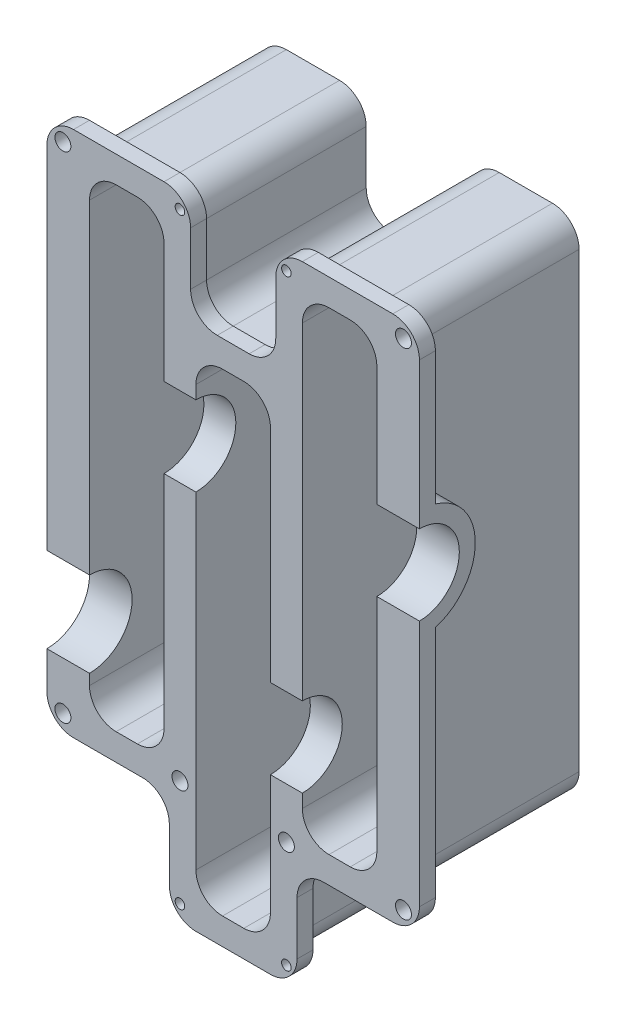
from build123d import *

# Parameters (mm, degrees)
SKETCH1_W           = 70
SKETCH1_H           = 119
BOSS_EXTRUDE1_DEPTH = 35
SKETCH2_R           = 8
CUT_EXTRUDE1_DEPTH  = 8
CUT_EXTRUDE2_DEPTH  = 32
SKETCH4_R           = 7.5
CUT_EXTRUDE3_DEPTH  = 8
SKETCH5_W           = 16
SKETCH5_H           = 20
SKETCH5_W_2         = 23
CUT_EXTRUDE4_DEPTH  = 36
CUT_EXTRUDE5_DEPTH  = 5
SKETCH7_W           = 18
SKETCH7_H           = 32
CUT_EXTRUDE6_DEPTH  = 2
SKETCH8_W           = 32
SKETCH8_H           = 22
CUT_EXTRUDE7_DEPTH  = 2
SKETCH9_W           = 22
SKETCH9_H           = 32
CUT_EXTRUDE8_DEPTH  = 2
SKETCH10_W          = 32
SKETCH10_H          = 18
CUT_EXTRUDE9_DEPTH  = 2
SKETCH11_W          = 25
SKETCH11_H          = 32
CUT_EXTRUDE10_DEPTH = 2
CUT_EXTRUDE11_DEPTH = 5
SKETCH13_W          = 22
SKETCH13_H          = 32
CUT_EXTRUDE12_DEPTH = 2
SKETCH14_W          = 32
SKETCH14_H          = 18
CUT_EXTRUDE17_DEPTH = 2
SKETCH18_W          = 18
SKETCH18_H          = 32
CUT_EXTRUDE18_DEPTH = 2
SKETCH20_W          = 32
SKETCH20_H          = 22
CUT_EXTRUDE19_DEPTH = 2
SKETCH21_W          = 20
SKETCH21_H          = 32
CUT_EXTRUDE20_DEPTH = 2
FILLET1_R           = 5
FILLET2_R           = 5
FILLET3_R           = 5
SKETCH23_R          = 1.5
CUT_EXTRUDE21_DEPTH = 10
SKETCH24_R          = 0.9
CUT_EXTRUDE22_DEPTH = 10
BOSS_EXTRUDE2_DEPTH = 6
BOSS_EXTRUDE3_DEPTH = 6


with BuildPart() as part:
    # Sketch1 → Boss-Extrude1 (new body)
    with BuildSketch(Plane.XY):
        Rectangle(SKETCH1_W, SKETCH1_H)
    extrude(amount=BOSS_EXTRUDE1_DEPTH)

    # Sketch2 → Cut-Extrude1 (cut)
    with BuildSketch(Plane.ZY.offset(35)):
        with Locations((35, -19.5)):
            Circle(SKETCH2_R)
    extrude(amount=-CUT_EXTRUDE1_DEPTH, mode=Mode.SUBTRACT)

    # Sketch3 → Cut-Extrude2 (cut)
    with BuildSketch(Plane.XY.offset(35)):
        Polygon((-27, 54.5), (-13, 54.5), (-13, 27), (-7, 27), (-7, 34.5), (7, 34.5), (7, -12), (13, -12), (13, 54.5), (27, 54.5), (27, -34.5), (13, -34.5), (13, -27), (7, -27), (7, -54.5), (-7, -54.5), (-7, 12), (-13, 12), (-13, -34.5), (-27, -34.5), align=None)
    extrude(amount=-CUT_EXTRUDE2_DEPTH, mode=Mode.SUBTRACT)

    # Sketch4 → Cut-Extrude3 (cut)
    with BuildSketch(Plane(origin=(35, 0, 0), x_dir=(0, 0, -1), z_dir=(1, 0, 0))):
        with Locations((-35, 19.5)):
            Circle(SKETCH4_R)
    extrude(amount=-CUT_EXTRUDE3_DEPTH, mode=Mode.SUBTRACT)

    # Sketch5 → Cut-Extrude4 (cut, through all)
    with BuildSketch(Plane.XY.offset(35)):
        with Locations((0, 49.5)):
            Rectangle(SKETCH5_W, SKETCH5_H)
        with Locations((-23.5, -49.5)):
            Rectangle(SKETCH5_W_2, SKETCH5_H)
        with Locations((23.5, -49.5)):
            Rectangle(SKETCH5_W_2, SKETCH5_H)
    extrude(amount=-CUT_EXTRUDE4_DEPTH, mode=Mode.SUBTRACT)

    # Sketch6 → Cut-Extrude5 (cut)
    with BuildSketch(Plane.ZY.offset(35)):
        with BuildLine():
            Line((0, -39.5), (0, 59.5))
            Line((0, 59.5), (32, 59.5))
            Line((32, 59.5), (32, -8.916994756))
            ThreePointArc((32, -8.916994756), (24, -19.5), (32, -30.083005244))
            Line((32, -30.083005244), (32, -39.5))
            Line((32, -39.5), (0, -39.5))
        make_face()
    extrude(amount=-CUT_EXTRUDE5_DEPTH, mode=Mode.SUBTRACT)

    # Sketch7 → Cut-Extrude6 (cut)
    with BuildSketch(Plane.XZ.offset(39.5)):
        with Locations((-21, 16)):
            Rectangle(SKETCH7_W, SKETCH7_H)
    extrude(amount=-CUT_EXTRUDE6_DEPTH, mode=Mode.SUBTRACT)

    # Sketch8 → Cut-Extrude7 (cut)
    with BuildSketch(Plane.ZY.offset(12)):
        with Locations((16, -48.5)):
            Rectangle(SKETCH8_W, SKETCH8_H)
    extrude(amount=-CUT_EXTRUDE7_DEPTH, mode=Mode.SUBTRACT)

    # Sketch9 → Cut-Extrude8 (cut)
    with BuildSketch(Plane.XZ.offset(59.5)):
        with Locations((1, 16)):
            Rectangle(SKETCH9_W, SKETCH9_H)
    extrude(amount=-CUT_EXTRUDE8_DEPTH, mode=Mode.SUBTRACT)

    # Sketch10 → Cut-Extrude9 (cut)
    with BuildSketch(Plane(origin=(12, 0, 0), x_dir=(0, 0, -1), z_dir=(1, 0, 0))):
        with Locations((-16, -48.5)):
            Rectangle(SKETCH10_W, SKETCH10_H)
    extrude(amount=-CUT_EXTRUDE9_DEPTH, mode=Mode.SUBTRACT)

    # Sketch11 → Cut-Extrude10 (cut)
    with BuildSketch(Plane.XZ.offset(39.5)):
        with Locations((22.5, 16)):
            Rectangle(SKETCH11_W, SKETCH11_H)
    extrude(amount=-CUT_EXTRUDE10_DEPTH, mode=Mode.SUBTRACT)

    # Sketch12 → Cut-Extrude11 (cut)
    with BuildSketch(Plane(origin=(35, 0, 0), x_dir=(0, 0, -1), z_dir=(1, 0, 0))):
        with BuildLine():
            Line((-32, 59.5), (0, 59.5))
            Line((0, 59.5), (0, -37.5))
            Line((0, -37.5), (-32, -37.5))
            Line((-32, -37.5), (-32, 9.437694101))
            ThreePointArc((-32, 9.437694101), (-24.5, 19.5), (-32, 29.562305899))
            Line((-32, 29.562305899), (-32, 59.5))
        make_face()
    extrude(amount=-CUT_EXTRUDE11_DEPTH, mode=Mode.SUBTRACT)

    # Sketch13 → Cut-Extrude12 (cut)
    with BuildSketch(Plane(origin=(0, 59.5, 0), x_dir=(1, 0, 0), z_dir=(0, 1, 0))):
        with Locations((19, -16)):
            Rectangle(SKETCH13_W, SKETCH13_H)
    extrude(amount=-CUT_EXTRUDE12_DEPTH, mode=Mode.SUBTRACT)

    # Sketch14 → Cut-Extrude17 (cut)
    with BuildSketch(Plane.ZY.offset(-8)):
        with Locations((16, 48.5)):
            Rectangle(SKETCH14_W, SKETCH14_H)
    extrude(amount=-CUT_EXTRUDE17_DEPTH, mode=Mode.SUBTRACT)

    # Sketch18 → Cut-Extrude18 (cut)
    with BuildSketch(Plane(origin=(0, 39.5, 0), x_dir=(1, 0, 0), z_dir=(0, 1, 0))):
        with Locations((1, -16)):
            Rectangle(SKETCH18_W, SKETCH18_H)
    extrude(amount=-CUT_EXTRUDE18_DEPTH, mode=Mode.SUBTRACT)

    # Sketch20 → Cut-Extrude19 (cut)
    with BuildSketch(Plane(origin=(-8, 0, 0), x_dir=(0, 0, -1), z_dir=(1, 0, 0))):
        with Locations((-16, 48.5)):
            Rectangle(SKETCH20_W, SKETCH20_H)
    extrude(amount=-CUT_EXTRUDE19_DEPTH, mode=Mode.SUBTRACT)

    # Sketch21 → Cut-Extrude20 (cut)
    with BuildSketch(Plane(origin=(0, 59.5, 0), x_dir=(1, 0, 0), z_dir=(0, 1, 0))):
        with Locations((-20, -16)):
            Rectangle(SKETCH21_W, SKETCH21_H)
    extrude(amount=-CUT_EXTRUDE20_DEPTH, mode=Mode.SUBTRACT)

    # Fillet1
    fillet1_edges = [part.edges().sort_by_distance(p)[0] for p in [
        (-27, -34.5, 19),
        (-27, 54.5, 19),
        (-13, 54.5, 19),
        (-7, 34.5, 19),
        (7, 34.5, 19),
        (13, 54.5, 19),
        (27, 54.5, 19),
        (27, -34.5, 19),
        (13, -34.5, 19),
        (7, -54.5, 19),
        (-7, -54.5, 19),
        (-13, -34.5, 19),
    ]]
    fillet(fillet1_edges, radius=FILLET1_R)

    # Fillet2
    fillet2_edges = [part.edges().sort_by_distance(p)[0] for p in [
        (-35, -39.5, 33.5),
        (-12, -39.5, 33.5),
        (-30, -37.5, 16),
        (-12, -59.5, 33.5),
        (-10, -37.5, 16),
        (12, -59.5, 33.5),
        (-10, -57.5, 16),
        (12, -39.5, 33.5),
        (10, -57.5, 16),
        (35, -39.5, 33.5),
        (10, -37.5, 16),
        (30, -37.5, 16),
    ]]
    fillet(fillet2_edges, radius=FILLET2_R)

    # Fillet3
    fillet3_edges = [part.edges().sort_by_distance(p)[0] for p in [
        (8, 59.5, 33.5),
        (30, 57.5, 16),
        (8, 39.5, 33.5),
        (10, 57.5, 16),
        (-8, 39.5, 33.5),
        (10, 37.5, 16),
        (-8, 59.5, 33.5),
        (-10, 37.5, 16),
        (-10, 57.5, 16),
        (-30, 57.5, 16),
        (-35, 59.5, 33.5),
        (35, 59.5, 33.5),
    ]]
    fillet(fillet3_edges, radius=FILLET3_R)

    # Sketch23 → Cut-Extrude21 (cut)
    with BuildSketch(Plane.XY.offset(35)):
        with Locations((-32, 56.5)):
            Circle(SKETCH23_R)
        with Locations((32, 56.5)):
            Circle(SKETCH23_R)
        with Locations((-32, -36.5)):
            Circle(SKETCH23_R)
        with Locations((32, -36.5)):
            Circle(SKETCH23_R)
        with Locations((-10, -36.5)):
            Circle(SKETCH23_R)
        with Locations((10, -36.5)):
            Circle(SKETCH23_R)
    extrude(amount=-CUT_EXTRUDE21_DEPTH, mode=Mode.SUBTRACT)

    # Sketch24 → Cut-Extrude22 (cut)
    with BuildSketch(Plane.XY.offset(35)):
        with Locations((-10, 56.5)):
            Circle(SKETCH24_R)
        with Locations((10, 56.5)):
            Circle(SKETCH24_R)
        with Locations((-10, -56.5)):
            Circle(SKETCH24_R)
        with Locations((10, -56.5)):
            Circle(SKETCH24_R)
    extrude(amount=-CUT_EXTRUDE22_DEPTH, mode=Mode.SUBTRACT)

    # Sketch25 → Boss-Extrude2 (add)
    with BuildSketch(Plane.ZY.offset(13)):
        with BuildLine():
            Line((35, 27), (3, 27))
            Line((3, 27), (3, 12))
            Line((3, 12), (35, 12))
            ThreePointArc((35, 12), (27.5, 19.5), (35, 27))
        make_face()
    extrude(amount=-BOSS_EXTRUDE2_DEPTH)

    # Sketch26 → Boss-Extrude3 (add)
    with BuildSketch(Plane.ZY.offset(-7)):
        with BuildLine():
            Line((35, -12), (3, -12))
            Line((3, -12), (3, -27))
            Line((3, -27), (35, -27))
            ThreePointArc((35, -27), (27.5, -19.5), (35, -12))
        make_face()
    extrude(amount=-BOSS_EXTRUDE3_DEPTH)


solid = part.part
